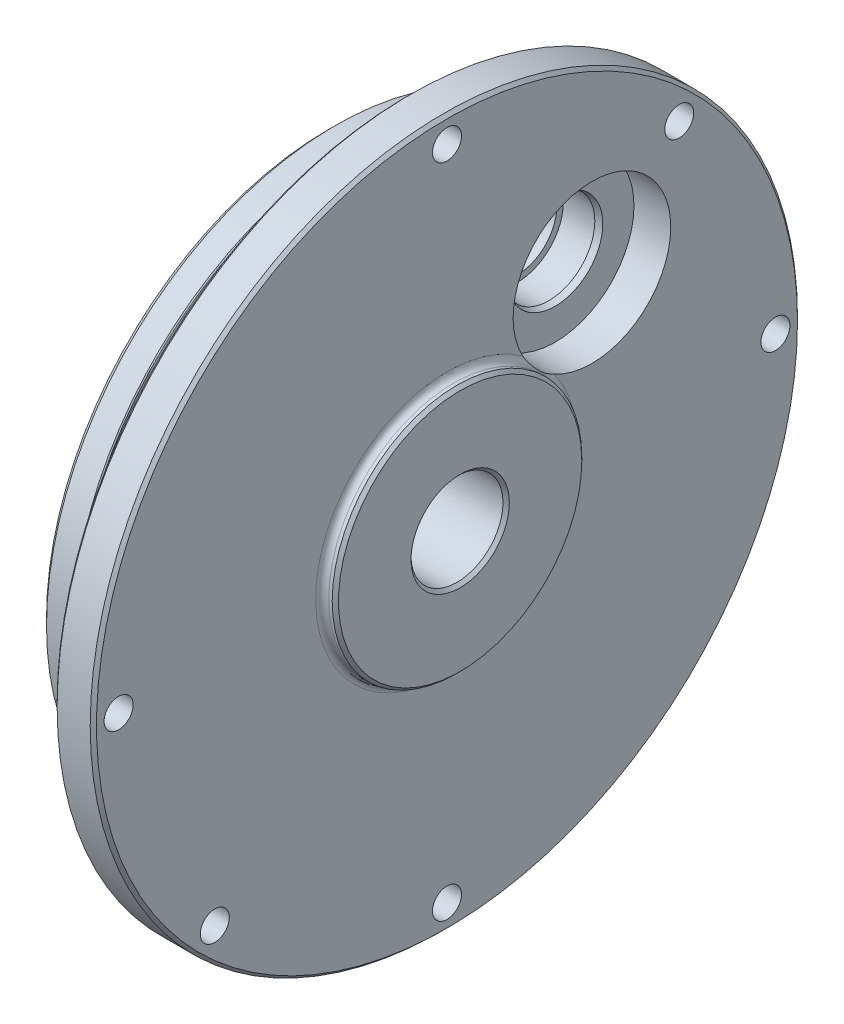
from build123d import *

# Parameters (mm, degrees)
SKETCH2_R                 = 15.08125
BOSS_EXTRUDE1_DEPTH       = 0.4191
SKETCH3_R                 = 15.08125
BOSS_EXTRUDE2_DEPTH       = 0.381
BOSS_EXTRUDE2_TAPER       = 45
M3_CLEARANCE_HOLE1_D      = 3.5052
M3_CLEARANCE_HOLE1_DEPTH  = 6.35
M10_CLEARANCE_HOLE1_D     = 11.1125
M10_CLEARANCE_HOLE1_DEPTH = 15.875
CHAMFER1_SIZE             = 0.381
CHAMFER2_SIZE             = 0.204177285
CHAMFER2_SIZE2            = 0.762
CHAMFER3_SIZE             = 0.7874
FILLET1_R                 = 0.127
FILLET2_R                 = 0.381


with BuildPart() as part:
    # Sketch1 → Revolve1 (revolve)
    with BuildSketch(Plane(origin=(0, 0, 0), x_dir=(-1, 0, 0), z_dir=(0, 0, -1))):
        with BuildLine():
            Line((-15.0749, 15.08125), (-15.0749, 0))
            Line((-15.0749, 0), (0, 0))
            Line((0, 0), (0, 34.8996))
            Line((0, 34.8996), (-3.937, 34.8996))
            Line((-3.937, 34.8996), (-3.937, 33.655))
            Line((-3.937, 33.655), (-6.35, 33.655))
            Line((-6.35, 33.655), (-6.35, 34.8996))
            Line((-6.35, 34.8996), (-9.525, 34.8996))
            Line((-9.525, 34.8996), (-9.525, 42.7355))
            Line((-9.525, 42.7355), (-14.2875, 42.7355))
            Line((-14.2875, 42.7355), (-14.2875, 15.86865))
            ThreePointArc((-14.2875, 15.86865), (-14.51812412, 15.31187412), (-15.0749, 15.08125))
        make_face()
    revolve(axis=Axis((15.074925, 0, 0), (-1, 0, 0)))

    # Sketch2 → Boss-Extrude1 (add)
    with BuildSketch(Plane(origin=(15.0749, 0, 0), x_dir=(0, 0, -1), z_dir=(1, 0, 0))):
        Circle(SKETCH2_R)
    extrude(amount=BOSS_EXTRUDE1_DEPTH)

    # Sketch3 → Boss-Extrude2 (add)
    with BuildSketch(Plane(origin=(15.494, 0, 0), x_dir=(0, 0, -1), z_dir=(1, 0, 0))):
        Circle(SKETCH3_R)
    extrude(amount=BOSS_EXTRUDE2_DEPTH, taper=BOSS_EXTRUDE2_TAPER)

    # Sketch4 → Cut-Revolve1 (revolve, cut)
    with BuildSketch(Plane.XY.offset(-17.511499436)):
        Polygon((0, 22.273999436), (0, 17.511499436), (14.600771391, 17.511499436), (14.600771391, 27.036499436), (9.8425, 27.036499436), (9.8425, 23.067749436), (5.2705, 23.067749436), (5.2705, 22.273999436), align=None)
    revolve(axis=Axis((0, 17.511499436, -17.511499436), (1, 0, 0)), mode=Mode.SUBTRACT)

    # M3 Clearance Hole1
    with Locations(Plane.ZY.offset(-9.525)):
        with Locations((28.063300378, -28.063300378), (-28.063300378, 28.063300378), (39.6875, 0), (-39.6875, 0), (0, -39.6875), (0, 39.6875)):
            Hole(M3_CLEARANCE_HOLE1_D / 2, depth=M3_CLEARANCE_HOLE1_DEPTH)

    # M10 Clearance Hole1
    with Locations(Plane(origin=(15.875, 0, 0), x_dir=(0, 0, -1), z_dir=(1, 0, 0))):
        with Locations((0, 0)):
            Hole(M10_CLEARANCE_HOLE1_D / 2, depth=M10_CLEARANCE_HOLE1_DEPTH)

    # Chamfer1
    chamfer1_edges = [part.edges().sort_by_distance(p)[0] for p in [
        (9.525, -42.7355, 0),
        (14.2875, -42.7355, 0),
        (15.875, 0, -5.55625),
        (0, 0, -5.55625),
    ]]
    chamfer(chamfer1_edges, length=CHAMFER1_SIZE)

    # Chamfer2
    chamfer2_edges = [part.edges().sort_by_distance(p)[0] for p in [
        (9.8425, 11.955249436, -17.511499436),
    ]]
    chamfer2_side = [part.faces().sort_by_distance(p)[0] for p in [
        (9.8425, 8.25590712, -17.511499436),
    ]]
    chamfer(chamfer2_edges, length=CHAMFER2_SIZE, length2=CHAMFER2_SIZE2, reference=chamfer2_side[0])

    # Chamfer3
    chamfer3_edges = [part.edges().sort_by_distance(p)[0] for p in [
        (0, -34.8996, 0),
    ]]
    chamfer(chamfer3_edges, length=CHAMFER3_SIZE)

    # Fillet1
    fillet1_edges = [part.edges().sort_by_distance(p)[0] for p in [
        (3.937, -34.8996, 0),
        (6.35, -34.8996, 0),
    ]]
    fillet(fillet1_edges, radius=FILLET1_R)

    # Fillet2
    fillet2_edges = [part.edges().sort_by_distance(p)[0] for p in [
        (3.937, -33.655, 0),
        (6.35, -33.655, 0),
    ]]
    fillet(fillet2_edges, radius=FILLET2_R)


solid = part.part
